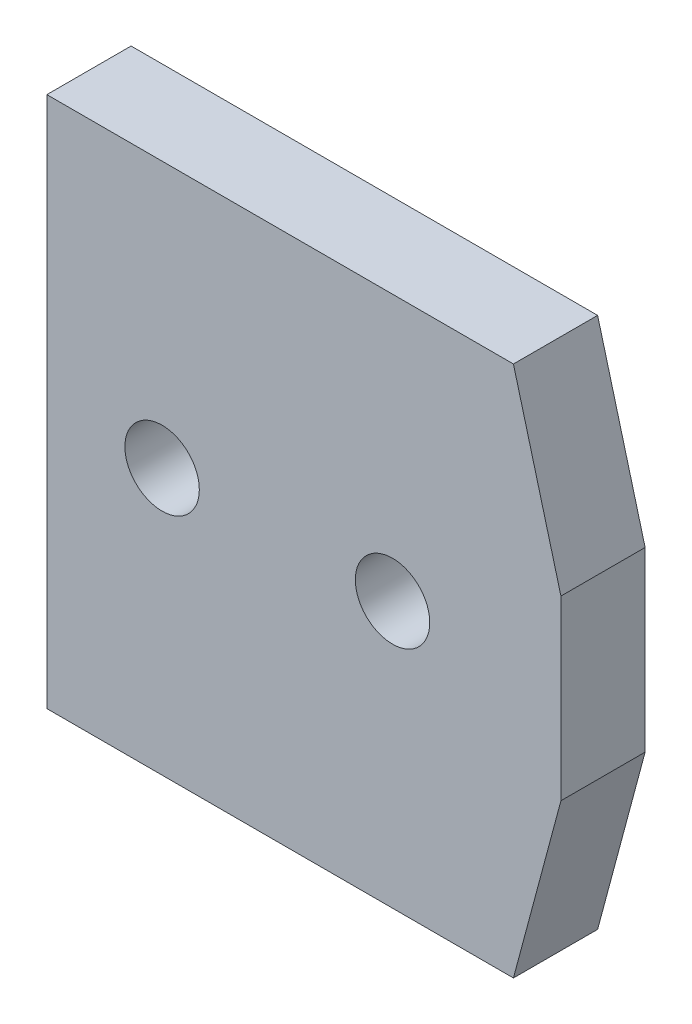
from build123d import *

# Parameters (mm, degrees)
SKIZZE1_R                       = 2.1
AUFSATZ_LINEAR_AUSTRAGEN1_DEPTH = 4.75


with BuildPart() as part:
    # Skizze1 → Aufsatz-Linear austragen1 (new body)
    with BuildSketch(Plane.XY):
        Polygon((-14.5, 15), (-14.5, -15), (11.820508076, -15), (14.5, -5), (14.5, 5), (11.820508076, 15), align=None)
        with Locations((5, 0)):
            Circle(SKIZZE1_R, mode=Mode.SUBTRACT)
        with Locations((-8, 0)):
            Circle(SKIZZE1_R, mode=Mode.SUBTRACT)
    extrude(amount=AUFSATZ_LINEAR_AUSTRAGEN1_DEPTH)


solid = part.part
